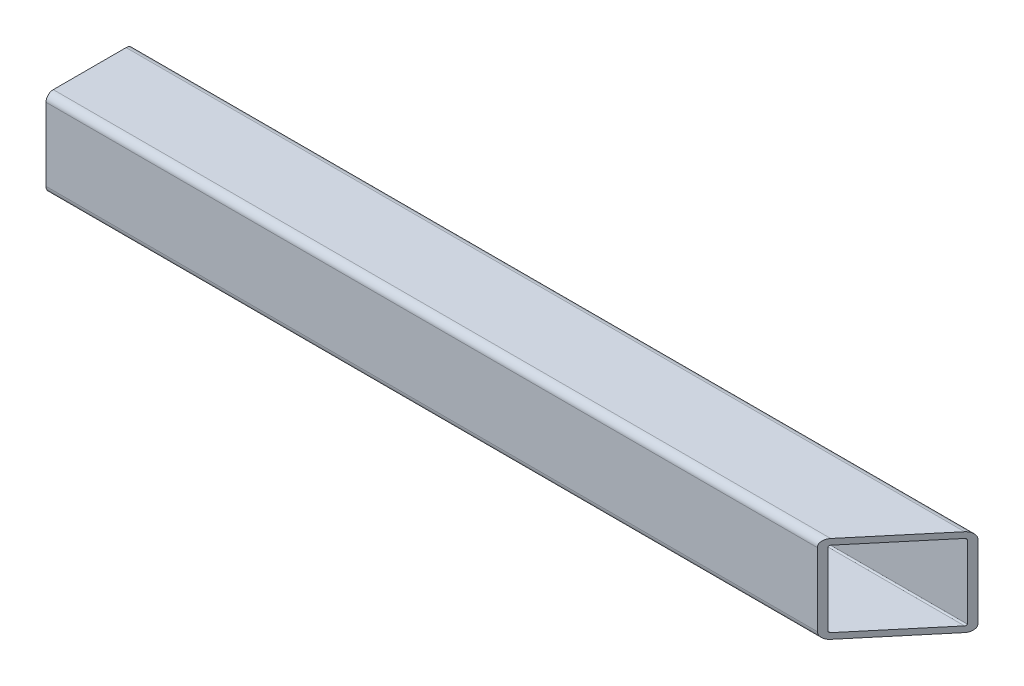
from build123d import *

# Parameters (mm, degrees)
EXTRUDE_THIN1_DEPTH     = 184.15
CUT_EXTRUDE1_DEPTH      = 1
CUT_EXTRUDE1_DEPTH_BACK = 39.1


with BuildPart() as part:
    # Sketch1 → Extrude-Thin1 (new body, symmetric)
    with BuildSketch(Plane(origin=(0, 0, 0), x_dir=(0, 0, -1), z_dir=(1, 0, 0))):
        with BuildLine():
            Line((-15.875, 19.05), (15.875, 19.05))
            ThreePointArc((15.875, 19.05), (18.12006403, 18.12006403), (19.05, 15.875))
            Line((19.05, 15.875), (19.05, -15.875))
            ThreePointArc((19.05, -15.875), (18.12006403, -18.12006403), (15.875, -19.05))
            Line((15.875, -19.05), (-15.875, -19.05))
            ThreePointArc((-15.875, -19.05), (-18.12006403, -18.12006403), (-19.05, -15.875))
            Line((-19.05, -15.875), (-19.05, 15.875))
            ThreePointArc((-19.05, 15.875), (-18.12006403, 18.12006403), (-15.875, 19.05))
        make_face()
        with BuildLine():
            Line((-15.875, 16.51), (15.875, 16.51))
            ThreePointArc((15.875, 16.51), (16.324012806, 16.324012806), (16.51, 15.875))
            Line((16.51, 15.875), (16.51, -15.875))
            ThreePointArc((16.51, -15.875), (16.324012806, -16.324012806), (15.875, -16.51))
            Line((15.875, -16.51), (-15.875, -16.51))
            ThreePointArc((-15.875, -16.51), (-16.324012806, -16.324012806), (-16.51, -15.875))
            Line((-16.51, -15.875), (-16.51, 15.875))
            ThreePointArc((-16.51, 15.875), (-16.324012806, 16.324012806), (-15.875, 16.51))
        make_face(mode=Mode.SUBTRACT)
    extrude(amount=EXTRUDE_THIN1_DEPTH, both=True)

    # Sketch3 → Cut-Extrude1 (cut, two sides)
    with BuildSketch(Plane(origin=(0, 19.05, 0), x_dir=(1, 0, 0), z_dir=(0, 1, 0))) as cut_extrude1_sk:
        Polygon((666.581957194, 593.990018168), (184.15, 19.05), (152.180304052, -19.05), (-330.251653142, -593.990018168), (819.628383194, -1558.853932556), (1816.46199353, -370.87389622), align=None)
    extrude(amount=CUT_EXTRUDE1_DEPTH, mode=Mode.SUBTRACT)
    extrude(cut_extrude1_sk.sketch, amount=-CUT_EXTRUDE1_DEPTH_BACK, mode=Mode.SUBTRACT)


solid = part.part
